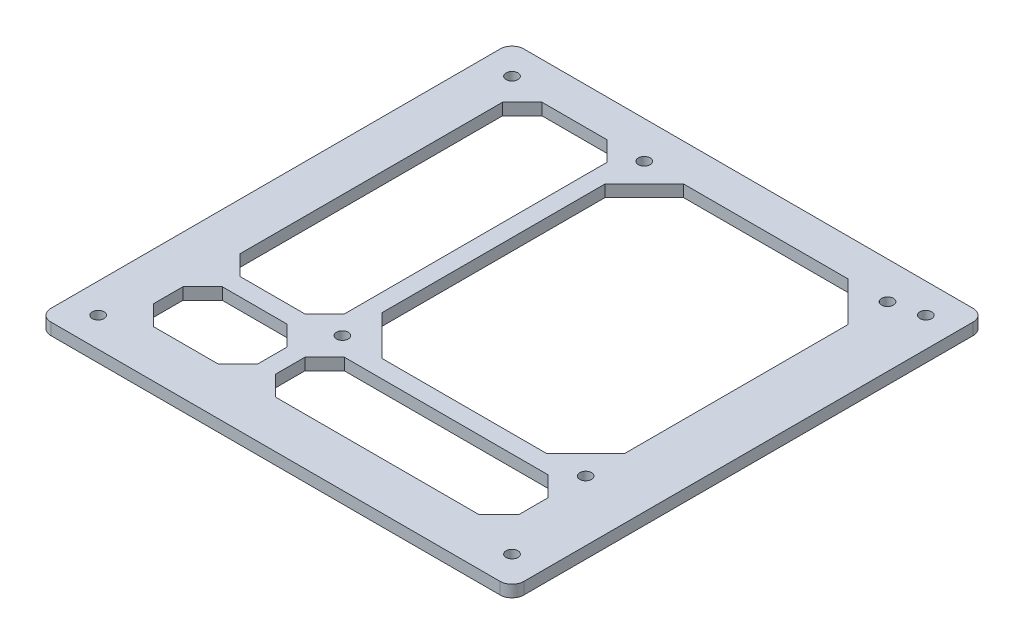
from build123d import *

# Parameters (mm, degrees)
SKETCH_1_R      = 1.5
EXTRUDE_1_DEPTH = 3


with BuildPart() as part:
    # 草圖1 → 填料-伸長1 (new body)
    with BuildSketch(Plane(origin=(0, 3, 0), x_dir=(1, 0, 0), z_dir=(0, 1, 0))):
        with BuildLine():
            Line((-60, 57), (-60, -57))
            ThreePointArc((-60, -57), (-59.121320344, -59.121320344), (-57, -60))
            Line((-57, -60), (57, -60))
            ThreePointArc((57, -60), (59.121320344, -59.121320344), (60, -57))
            Line((60, -57), (60, 57))
            ThreePointArc((60, 57), (59.121320344, 59.121320344), (57, 60))
            Line((57, 60), (-57, 60))
            ThreePointArc((-57, 60), (-59.121320344, 59.121320344), (-60, 57))
        make_face()
        with Locations((-17.035, 50.6)):
            Circle(SKETCH_1_R, mode=Mode.SUBTRACT)
        with Locations((44.685, 50.6)):
            Circle(SKETCH_1_R, mode=Mode.SUBTRACT)
        with Locations((44.685, -26)):
            Circle(SKETCH_1_R, mode=Mode.SUBTRACT)
        with Locations((-17.035, -26)):
            Circle(SKETCH_1_R, mode=Mode.SUBTRACT)
        with Locations((52.5, -52.5)):
            Circle(SKETCH_1_R, mode=Mode.SUBTRACT)
        with Locations((-52.5, 52.5)):
            Circle(SKETCH_1_R, mode=Mode.SUBTRACT)
        with Locations((52.5, 52.5)):
            Circle(SKETCH_1_R, mode=Mode.SUBTRACT)
        with Locations((-52.5, -52.5)):
            Circle(SKETCH_1_R, mode=Mode.SUBTRACT)
        Polygon((-48, -21), (-48, 45.6), (-43, 50.6), (-26.535, 50.6), (-21.535, 45.6), (-21.535, -21), (-26.535, -26), (-43, -26), align=None, mode=Mode.SUBTRACT)
        Polygon((-17.035, -43), (-17.035, -35.5), (-12.035, -30.5), (39.685, -30.5), (44.685, -35.5), (44.685, -43), (39.685, -48), (-12.035, -48), align=None, mode=Mode.SUBTRACT)
        Polygon((-48, -43), (-48, -35.5), (-43, -30.5), (-26.535, -30.5), (-21.535, -35.5), (-21.535, -43), (-26.535, -48), (-43, -48), align=None, mode=Mode.SUBTRACT)
        Polygon((-7.035, 50.6), (34.685, 50.6), (44.685, 40.6), (44.685, -16), (34.685, -26), (-7.035, -26), (-17.035, -16), (-17.035, 40.6), align=None, mode=Mode.SUBTRACT)
    extrude(amount=-EXTRUDE_1_DEPTH)


solid = part.part
